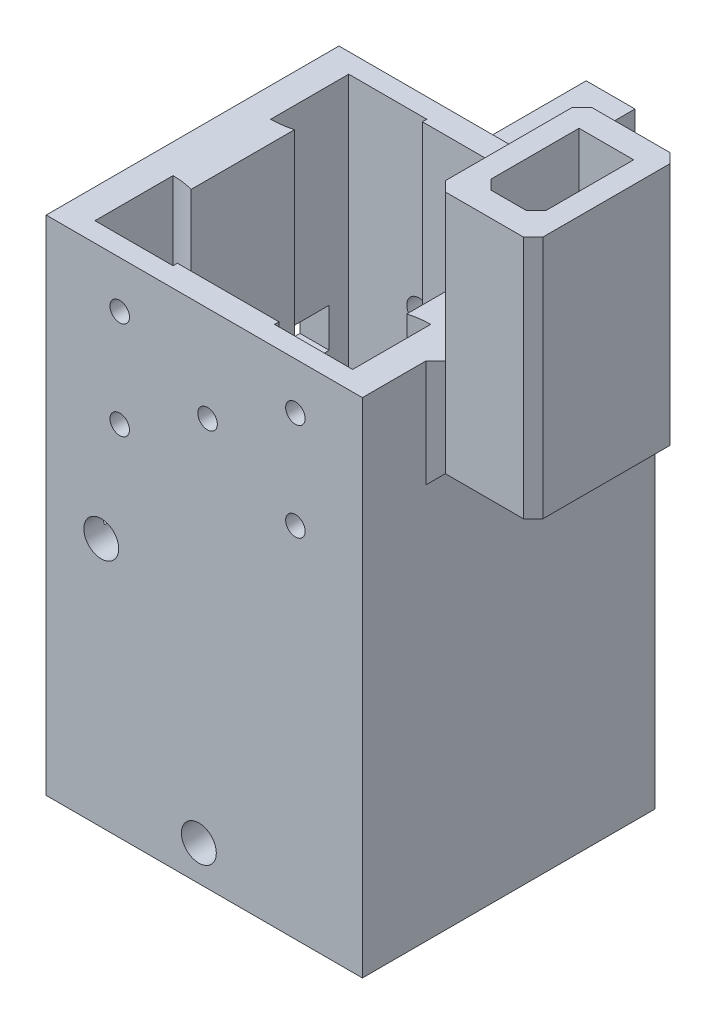
from build123d import *

# Parameters (mm, degrees)
SKETCH1_W                         = 32.4
SKETCH1_H                         = 30
SKETCH1_R                         = 1.75
BOSS_EXTRUDE1_DEPTH               = 25
SKETCH2_R                         = 4
CUT_EXTRUDE1_DEPTH                = 20
SKETCH3_W                         = 32.4
SKETCH3_H                         = 30
SKETCH3_R                         = 4
BOSS_EXTRUDE2_DEPTH               = 3
SKETCH4_W                         = 32.4
SKETCH4_H                         = 30
BOSS_EXTRUDE3_DEPTH               = 23.5
SKETCH5_R                         = 1.25
CUT_EXTRUDE2_DEPTH                = 2.45
SKETCH6_W                         = 22
SKETCH6_H                         = 4
CUT_EXTRUDE3_DEPTH                = 5.15
SKETCH7_W                         = 15
SKETCH7_H                         = 10
BOSS_EXTRUDE4_DEPTH               = 10
SKETCH8_W                         = 5.6
SKETCH8_H                         = 10
CUT_EXTRUDE4_DEPTH                = 15
CHAMFER1_SIZE                     = 1
SKETCH11_R                        = 1
CUT_EXTRUDE5_DEPTH                = 5
CHAMFER3_SIZE                     = 1
BOSS_EXTRUDE6_DEPTH               = 15
CHAMFER5_SIZE                     = 1
F_3_32_0_140625_DOWEL_HOLE1_D     = 3.571875
F_3_32_0_140625_DOWEL_HOLE1_DEPTH = 12.7
F_3_32_0_140625_DOWEL_HOLE1_TIP   = 1.073099512
SKETCH19_W                        = 5
SKETCH19_H                        = 7
BOSS_EXTRUDE7_DEPTH               = 25


with BuildPart() as part:
    # Sketch1 → Boss-Extrude1 (new body)
    with BuildSketch(Plane(origin=(0, 0, 0), x_dir=(1, 0, 0), z_dir=(0, 1, 0))):
        with Locations((16.2, -15)):
            Rectangle(SKETCH1_W, SKETCH1_H)
        with Locations((6.2, -5)):
            Circle(SKETCH1_R, mode=Mode.SUBTRACT)
        with Locations((26.2, -5)):
            Circle(SKETCH1_R, mode=Mode.SUBTRACT)
        with Locations((26.2, -25)):
            Circle(SKETCH1_R, mode=Mode.SUBTRACT)
        with Locations((6.2, -25)):
            Circle(SKETCH1_R, mode=Mode.SUBTRACT)
    extrude(amount=BOSS_EXTRUDE1_DEPTH)

    # Sketch2 → Cut-Extrude1 (cut)
    with BuildSketch(Plane(origin=(0, 25, 0), x_dir=(1, 0, 0), z_dir=(0, 1, 0))):
        with Locations((16.2, -15)):
            Circle(SKETCH2_R)
    extrude(amount=-CUT_EXTRUDE1_DEPTH, mode=Mode.SUBTRACT)

    # Sketch3 → Boss-Extrude2 (add)
    with BuildSketch(Plane(origin=(0, 25, 0), x_dir=(1, 0, 0), z_dir=(0, 1, 0))):
        with Locations((16.2, -15)):
            Rectangle(SKETCH3_W, SKETCH3_H)
        Polygon((3, -20), (3, -10), (3, -2), (11, -2), (21.4, -2), (29.4, -2), (29.4, -10), (29.4, -20), (29.4, -28), (21.4, -28), (11, -28), (3, -28), align=None, mode=Mode.SUBTRACT)
        with BuildLine():
            ThreePointArc((11, -2), (8.656854249, -7.656854249), (3, -10))
            Line((3, -10), (3, -20))
            ThreePointArc((3, -20), (8.656854249, -22.343145751), (11, -28))
            Line((11, -28), (21.4, -28))
            ThreePointArc((21.4, -28), (23.743145751, -22.343145751), (29.4, -20))
            Line((29.4, -20), (29.4, -10))
            ThreePointArc((29.4, -10), (23.743145751, -7.656854249), (21.4, -2))
            Line((21.4, -2), (11, -2))
        make_face()
        with Locations((16.2, -15)):
            Circle(SKETCH3_R, mode=Mode.SUBTRACT)
    extrude(amount=BOSS_EXTRUDE2_DEPTH)

    # Sketch4 → Boss-Extrude3 (add)
    with BuildSketch(Plane(origin=(0, 28, 0), x_dir=(1, 0, 0), z_dir=(0, 1, 0))):
        with Locations((16.2, -15)):
            Rectangle(SKETCH4_W, SKETCH4_H)
        with BuildLine():
            Line((5.15, -20.294320277), (5.15, -9.705679723))
            ThreePointArc((5.15, -9.705679723), (4.085025855, -9.926078406), (3, -10))
            Line((3, -10), (3, -2))
            Line((3, -2), (11, -2))
            ThreePointArc((11, -2), (10.996832804, -2.225089113), (10.987333723, -2.45))
            Line((10.987333723, -2.45), (21.412666277, -2.45))
            ThreePointArc((21.412666277, -2.45), (21.403167196, -2.225089113), (21.4, -2))
            Line((21.4, -2), (29.4, -2))
            Line((29.4, -2), (29.4, -10))
            ThreePointArc((29.4, -10), (28.314974145, -9.926078406), (27.25, -9.705679723))
            Line((27.25, -9.705679723), (27.25, -20.294320277))
            ThreePointArc((27.25, -20.294320277), (28.314974145, -20.073921594), (29.4, -20))
            Line((29.4, -20), (29.4, -28))
            Line((29.4, -28), (21.4, -28))
            ThreePointArc((21.4, -28), (21.403167196, -27.774910887), (21.412666277, -27.55))
            Line((21.412666277, -27.55), (10.987333723, -27.55))
            ThreePointArc((10.987333723, -27.55), (10.996832804, -27.774910887), (11, -28))
            Line((11, -28), (3, -28))
            Line((3, -28), (3, -20))
            ThreePointArc((3, -20), (4.085025855, -20.073921594), (5.15, -20.294320277))
        make_face(mode=Mode.SUBTRACT)
    extrude(amount=BOSS_EXTRUDE3_DEPTH)

    # Sketch5 → Cut-Extrude2 (cut)
    with BuildSketch(Plane(origin=(0, 0, 0), x_dir=(-1, 0, 0), z_dir=(0, 0, -1))):
        with Locations((-22.2, 49)):
            Circle(SKETCH5_R)
        with Locations((-10.2, 34)):
            Circle(SKETCH5_R)
    extrude(amount=-CUT_EXTRUDE2_DEPTH, mode=Mode.SUBTRACT)

    # Sketch6 → Cut-Extrude3 (cut)
    with BuildSketch(Plane.ZY):
        with Locations((15, 30)):
            Rectangle(SKETCH6_W, SKETCH6_H)
    extrude(amount=-CUT_EXTRUDE3_DEPTH, mode=Mode.SUBTRACT)

    # Sketch7 → Boss-Extrude4 (add)
    with BuildSketch(Plane(origin=(32.4, 0, 0), x_dir=(0, 0, -1), z_dir=(1, 0, 0))):
        with Locations((-15, 46.5)):
            Rectangle(SKETCH7_W, SKETCH7_H)
    extrude(amount=BOSS_EXTRUDE4_DEPTH)

    # Sketch8 → Cut-Extrude4 (cut)
    with BuildSketch(Plane(origin=(0, 51.5, 0), x_dir=(1, 0, 0), z_dir=(0, 1, 0))):
        with Locations((37.4, -15)):
            Rectangle(SKETCH8_W, SKETCH8_H)
    extrude(amount=-CUT_EXTRUDE4_DEPTH, mode=Mode.SUBTRACT)

    # Chamfer1
    chamfer1_edges = [part.edges().sort_by_distance(p)[0] for p in [
        (34.6, 46.5, 20),
        (40.2, 46.5, 20),
    ]]
    chamfer(chamfer1_edges, length=CHAMFER1_SIZE)

    # Sketch11 → Cut-Extrude5 (cut)
    with BuildSketch(Plane.XY.offset(30)):
        with Locations((7.535754107, 46.7)):
            Circle(SKETCH11_R)
        with Locations((25.535754107, 46.7)):
            Circle(SKETCH11_R)
        with Locations((7.535754107, 36.7)):
            Circle(SKETCH11_R)
        with Locations((25.535754107, 36.7)):
            Circle(SKETCH11_R)
        with Locations((16.535754107, 41.7)):
            Circle(SKETCH11_R)
    extrude(amount=-CUT_EXTRUDE5_DEPTH, mode=Mode.SUBTRACT)

    # Chamfer3
    chamfer3_edges = [part.edges().sort_by_distance(p)[0] for p in [
        (32.4, 46.5, 7.5),
        (32.4, 46.5, 22.5),
        (32.4, 41.5, 15),
        (42.4, 46.5, 7.5),
        (42.4, 46.5, 22.5),
    ]]
    chamfer(chamfer3_edges, length=CHAMFER3_SIZE)

    # Sketch15 → Boss-Extrude6 (add)
    with BuildSketch(Plane(origin=(0, 51.5, 0), x_dir=(1, 0, 0), z_dir=(0, 1, 0))):
        Polygon((32.4, -7.5), (41.4, -7.5), (42.4, -8.5), (42.4, -21.5), (41.4, -22.5), (32.4, -22.5), align=None)
        Polygon((34.6, -10), (34.6, -19), (35.6, -20), (39.2, -20), (40.2, -19), (40.2, -10), align=None, mode=Mode.SUBTRACT)
    extrude(amount=BOSS_EXTRUDE6_DEPTH)

    # Chamfer5
    chamfer5_edges = [part.edges().sort_by_distance(p)[0] for p in [
        (32.4, 59, 7.5),
        (32.4, 59, 22.5),
    ]]
    chamfer(chamfer5_edges, length=CHAMFER5_SIZE)

    # 3/32 (0.140625) Dowel Hole1
    with Locations(Plane.XY.offset(30)):
        with Locations((5.645879952, 25.599824203), (15.645879952, 3.599824203)):
            Hole(F_3_32_0_140625_DOWEL_HOLE1_D / 2, depth=F_3_32_0_140625_DOWEL_HOLE1_DEPTH)
            with Locations((0, 0, -(F_3_32_0_140625_DOWEL_HOLE1_DEPTH + F_3_32_0_140625_DOWEL_HOLE1_TIP / 2))):  # 118° drill point
                Cone(0, F_3_32_0_140625_DOWEL_HOLE1_D / 2, F_3_32_0_140625_DOWEL_HOLE1_TIP, mode=Mode.SUBTRACT)

    # Sketch19 → Boss-Extrude7 (add)
    with BuildSketch(Plane(origin=(0, 0, 0), x_dir=(-1, 0, 0), z_dir=(0, 0, -1))):
        with Locations((-2.83125, 32.5777)):
            Rectangle(SKETCH19_W, SKETCH19_H)
    extrude(amount=BOSS_EXTRUDE7_DEPTH)


solid = part.part
